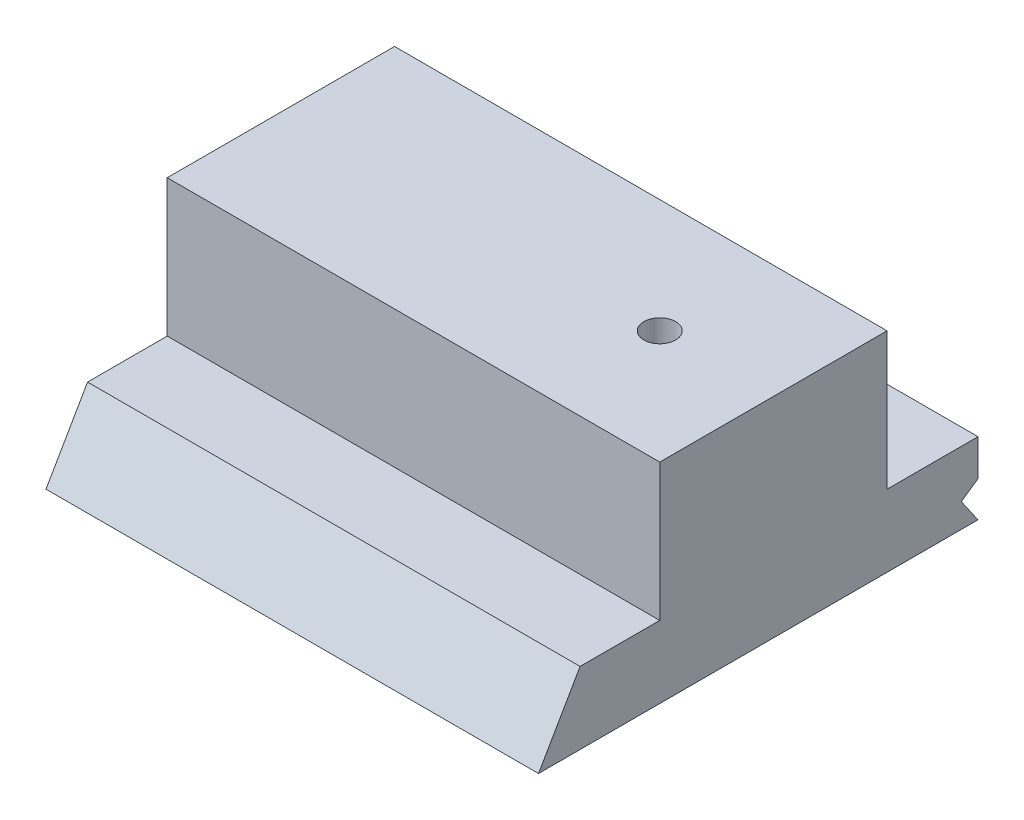
from build123d import *

# Parameters (mm, degrees)
SKETCH1_W      = 65
SKETCH1_H      = 58
EXTRUDE1_DEPTH = 9.5
EXTRUDE2_DEPTH = 66
EXTRUDE3_DEPTH = 66
SKETCH4_W      = 30
SKETCH4_H      = 18.1
EXTRUDE4_DEPTH = 65
SKETCH5_R      = 2.1
EXTRUDE5_DEPTH = 28.6
SKETCH6_R      = 4
EXTRUDE6_DEPTH = 20


with BuildPart() as part:
    # Sketch1 → Extrude1 (new body)
    with BuildSketch(Plane(origin=(0, 0, 0), x_dir=(1, 0, 0), z_dir=(0, 1, 0))):
        with Locations((32.5, 29)):
            Rectangle(SKETCH1_W, SKETCH1_H)
    extrude(amount=EXTRUDE1_DEPTH)

    # Sketch2 → Extrude2 (cut, through all)
    with BuildSketch(Plane(origin=(65, 0, 0), x_dir=(0, 0, -1), z_dir=(1, 0, 0))):
        Polygon((0, 0), (5.484827557, 9.5), (0, 9.5), align=None)
    extrude(amount=-EXTRUDE2_DEPTH, mode=Mode.SUBTRACT)

    # Sketch3 → Extrude3 (cut, through all)
    with BuildSketch(Plane(origin=(65, 0, 0), x_dir=(0, 0, -1), z_dir=(1, 0, 0))):
        Polygon((58, 0), (58, 4.7), (55.8, 3.176135582), align=None)
    extrude(amount=-EXTRUDE3_DEPTH, mode=Mode.SUBTRACT)

    # Sketch4 → Extrude4 (add)
    with BuildSketch(Plane.ZY):
        with Locations((-31, 18.55)):
            Rectangle(SKETCH4_W, SKETCH4_H)
    extrude(amount=-EXTRUDE4_DEPTH)

    # Sketch5 → Extrude5 (cut, through all)
    with BuildSketch(Plane(origin=(0, 27.6, 0), x_dir=(1, 0, 0), z_dir=(0, 1, 0))):
        with Locations(Location((50, 31, 0), (0, 0, 270))):  # turned: the seam where the file's is
            Circle(SKETCH5_R)
    extrude(amount=-EXTRUDE5_DEPTH, mode=Mode.SUBTRACT)

    # Sketch6 → Extrude6 (cut)
    with BuildSketch(Plane.XZ):
        with Locations(Location((50, -31, 0), (0, 0, 270))):  # turned: the seam where the file's is
            Circle(SKETCH6_R)
    extrude(amount=-EXTRUDE6_DEPTH, mode=Mode.SUBTRACT)


solid = part.part
